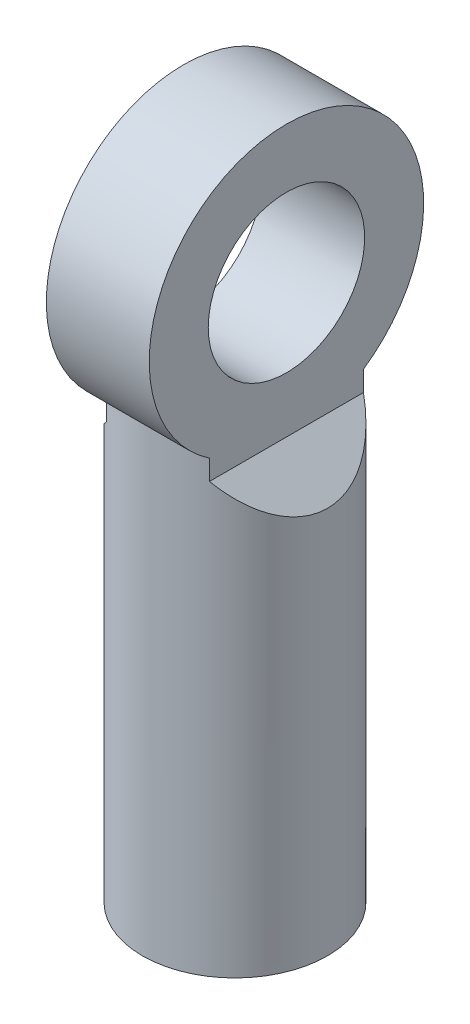
from build123d import *

# Parameters (mm, degrees)
SKETCH1_R                       = 3.429
BOSS_EXTRUDE1_DEPTH             = 24.384
CUT_EXTRUDE1_DEPTH              = 26.561096631
BOSS_EXTRUDE2_REACH             = 26.862
SKETCH3_R                       = 5.08
BOSS_EXTRUDE2_DIRECTION_2_REACH = 26.862
M6X1_0_TAPPED_HOLE1_D           = 5
M6X1_0_TAPPED_HOLE1_DEPTH       = 14.986
M6X1_0_TAPPED_HOLE1_TIP         = 1.502151548
F_12_CLEARANCE_HOLE1_D          = 5.7912


with BuildPart() as part:
    # Sketch1 → Boss-Extrude1 (new body)
    with BuildSketch(Plane(origin=(0, 0, 0), x_dir=(1, 0, 0), z_dir=(0, 1, 0))):
        Circle(SKETCH1_R)
    extrude(amount=BOSS_EXTRUDE1_DEPTH)

    # Sketch2 → Cut-Extrude1 (cut, through all)
    with BuildSketch(Plane.XY.offset(3.429)):
        Polygon((-1.905, 15.875), (-1.905, 24.384), (-5.334, 24.384), (-5.334, 12.446), align=None)
        Polygon((1.905, 15.875), (1.905, 24.384), (5.334, 24.384), (5.334, 12.446), align=None)
    extrude(amount=-CUT_EXTRUDE1_DEPTH, mode=Mode.SUBTRACT)

    # Boss-Extrude2: up to this face of the body (flat: up to its plane)
    boss_extrude2_end = Plane(part.part.faces().sort_by_distance((-1.905, 20.1295, 0))[0])
    # Sketch3 → Boss-Extrude2 (add, up to the picked face)
    with BuildSketch(Plane.ZY, mode=Mode.PRIVATE) as boss_extrude2_sk1:
        with Locations((0, 20.828)):
            Circle(SKETCH3_R)
    boss_extrude2_tool1 = split(extrude(boss_extrude2_sk1.sketch, amount=BOSS_EXTRUDE2_REACH, mode=Mode.PRIVATE), bisect_by=boss_extrude2_end, keep=Keep.BOTH, mode=Mode.PRIVATE)
    add(boss_extrude2_tool1.solids().sort_by(Axis((0, 20.828, 0), (-1, 0, 0)))[0])

    # Boss-Extrude2 direction 2: up to this face of the body (flat: up to its plane)
    boss_extrude2_direction_2_end = Plane(part.part.faces().sort_by_distance((1.905, 20.1295, 0))[0])
    # Sketch3 → Boss-Extrude2 direction 2 (add, up to the picked face)
    with BuildSketch(Plane.ZY, mode=Mode.PRIVATE) as boss_extrude2_direction_2_sk1:
        with Locations((0, 20.828)):
            Circle(SKETCH3_R)
    boss_extrude2_direction_2_tool1 = split(extrude(boss_extrude2_direction_2_sk1.sketch, amount=-BOSS_EXTRUDE2_DIRECTION_2_REACH, mode=Mode.PRIVATE), bisect_by=boss_extrude2_direction_2_end, keep=Keep.BOTH, mode=Mode.PRIVATE)
    add(boss_extrude2_direction_2_tool1.solids().sort_by(Axis((0, 20.828, 0), (1, 0, 0)))[0])

    # M6x1.0 Tapped Hole1
    with Locations(Plane(origin=(0, 0, 0), x_dir=(-1, 0, 0), z_dir=(0, -1, 0))):
        with Locations((0, 0)):
            Hole(M6X1_0_TAPPED_HOLE1_D / 2, depth=M6X1_0_TAPPED_HOLE1_DEPTH)
            with Locations((0, 0, -(M6X1_0_TAPPED_HOLE1_DEPTH + M6X1_0_TAPPED_HOLE1_TIP / 2))):  # 118° drill point
                Cone(0, M6X1_0_TAPPED_HOLE1_D / 2, M6X1_0_TAPPED_HOLE1_TIP, mode=Mode.SUBTRACT)

    # #12 Clearance Hole1 (through all)
    with Locations(Plane.ZY.offset(1.905)):
        with Locations((0, 20.828)):
            Hole(F_12_CLEARANCE_HOLE1_D / 2)


solid = part.part
